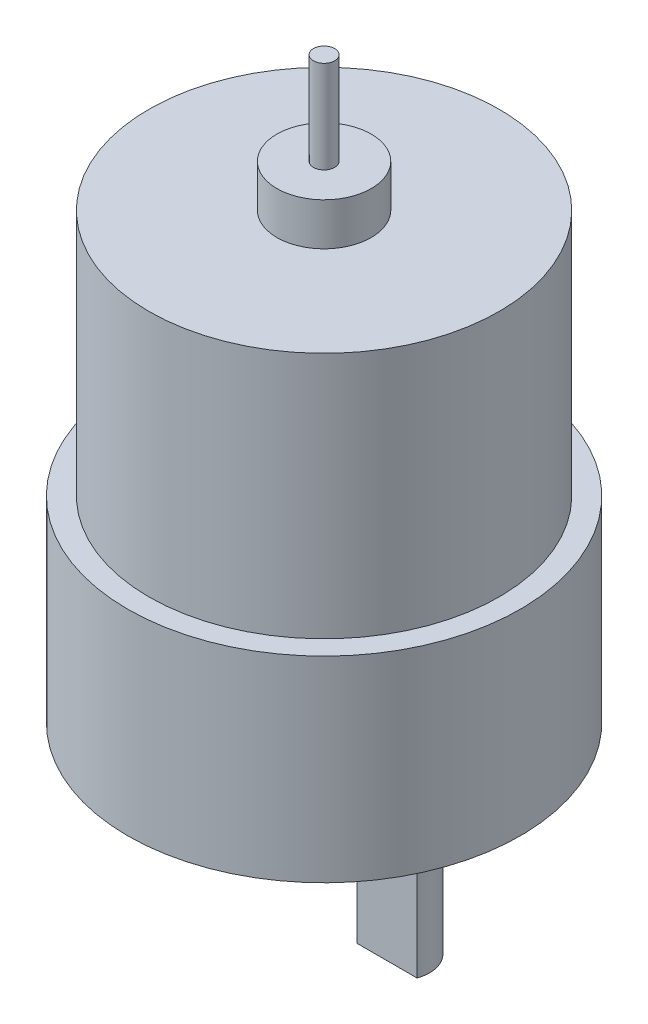
from build123d import *

# Parameters (mm, degrees)
SCHIZZO1_W                   = 18.5
SCHIZZO1_H                   = 18.4912
SCHIZZO2_R                   = 6
ESTRUSIONE_ESTRUSIONE1_DEPTH = 4.572
SCHIZZO3_R                   = 3
ESTRUSIONE_ESTRUSIONE2_DEPTH = 17.83
TAGLIO_ESTRUSIONE1_DEPTH     = 11.98
SCHIZZO5_R                   = 16.5
ESTRUSIONE_ESTRUSIONE3_DEPTH = 23.2918
SCHIZZO6_R                   = 4.445
ESTRUSIONE_ESTRUSIONE4_DEPTH = 4
SCHIZZO7_R                   = 1
ESTRUSIONE_ESTRUSIONE5_DEPTH = 8.7
FORO_3_0_3_1_D               = 3
FORO_3_0_3_1_DEPTH           = 6
FORO_3_0_3_2_D               = 3
FORO_3_0_3_2_DEPTH           = 10


with BuildPart() as part:
    # Schizzo1 → Rivoluzione1 (revolve)
    with BuildSketch(Plane(origin=(0, 0, 0), x_dir=(-1, 0, 0), z_dir=(0, 0, -1))):
        with Locations((-9.25, 0)):
            Rectangle(SCHIZZO1_W, SCHIZZO1_H)
    revolve(axis=Axis((0, -9.2456, 0), (0, 1, 0)))

    # Schizzo2 → Estrusione-Estrusione1 (add)
    with BuildSketch(Plane.XZ.offset(9.2456)):
        with Locations((0, -6.95)):
            Circle(SCHIZZO2_R)
    extrude(amount=ESTRUSIONE_ESTRUSIONE1_DEPTH)

    # Schizzo3 → Estrusione-Estrusione2 (add)
    with BuildSketch(Plane.XZ.offset(13.8176)):
        with Locations((0, -6.95)):
            Circle(SCHIZZO3_R)
    extrude(amount=ESTRUSIONE_ESTRUSIONE2_DEPTH)

    # Schizzo4 → Taglio-Estrusione1 (cut)
    with BuildSketch(Plane.XZ.offset(31.6476)):
        with BuildLine():
            Line((-2.821661699, -5.931066609), (2.821661699, -5.931066609))
            ThreePointArc((2.821661699, -5.931066609), (0, -3.95), (-2.821661699, -5.931066609))
        make_face()
    extrude(amount=-TAGLIO_ESTRUSIONE1_DEPTH, mode=Mode.SUBTRACT)

    # Schizzo5 → Estrusione-Estrusione3 (add)
    with BuildSketch(Plane(origin=(0, 9.2456, 0), x_dir=(-1, 0, 0), z_dir=(0, 1, 0))):
        Circle(SCHIZZO5_R)
    extrude(amount=ESTRUSIONE_ESTRUSIONE3_DEPTH)

    # Schizzo6 → Estrusione-Estrusione4 (add)
    with BuildSketch(Plane(origin=(0, 32.5374, 0), x_dir=(-1, 0, 0), z_dir=(0, 1, 0))):
        Circle(SCHIZZO6_R)
    extrude(amount=ESTRUSIONE_ESTRUSIONE4_DEPTH)

    # Schizzo7 → Estrusione-Estrusione5 (add)
    with BuildSketch(Plane(origin=(0, 36.5374, 0), x_dir=(-1, 0, 0), z_dir=(0, 1, 0))):
        Circle(SCHIZZO7_R)
    extrude(amount=ESTRUSIONE_ESTRUSIONE5_DEPTH)

    # Foro Ø3.0 (3)-1
    with Locations(Plane(origin=(0, -9.2456, 0), x_dir=(-1, 0, 0), z_dir=(0, -1, 0))):
        with Locations((15.5, 0), (7.75, -13.423393759), (-15.5, 0), (7.75, 13.423393759)):
            Hole(FORO_3_0_3_1_D / 2, depth=FORO_3_0_3_1_DEPTH)

    # Foro Ø3.0 (3)-2
    with Locations(Plane(origin=(0, -9.2456, 0), x_dir=(-1, 0, 0), z_dir=(0, -1, 0))):
        with Locations((13.8545119, 6.95), (-13.8545119, 6.95), (0, -15.5)):
            Hole(FORO_3_0_3_2_D / 2, depth=FORO_3_0_3_2_DEPTH)


solid = part.part
